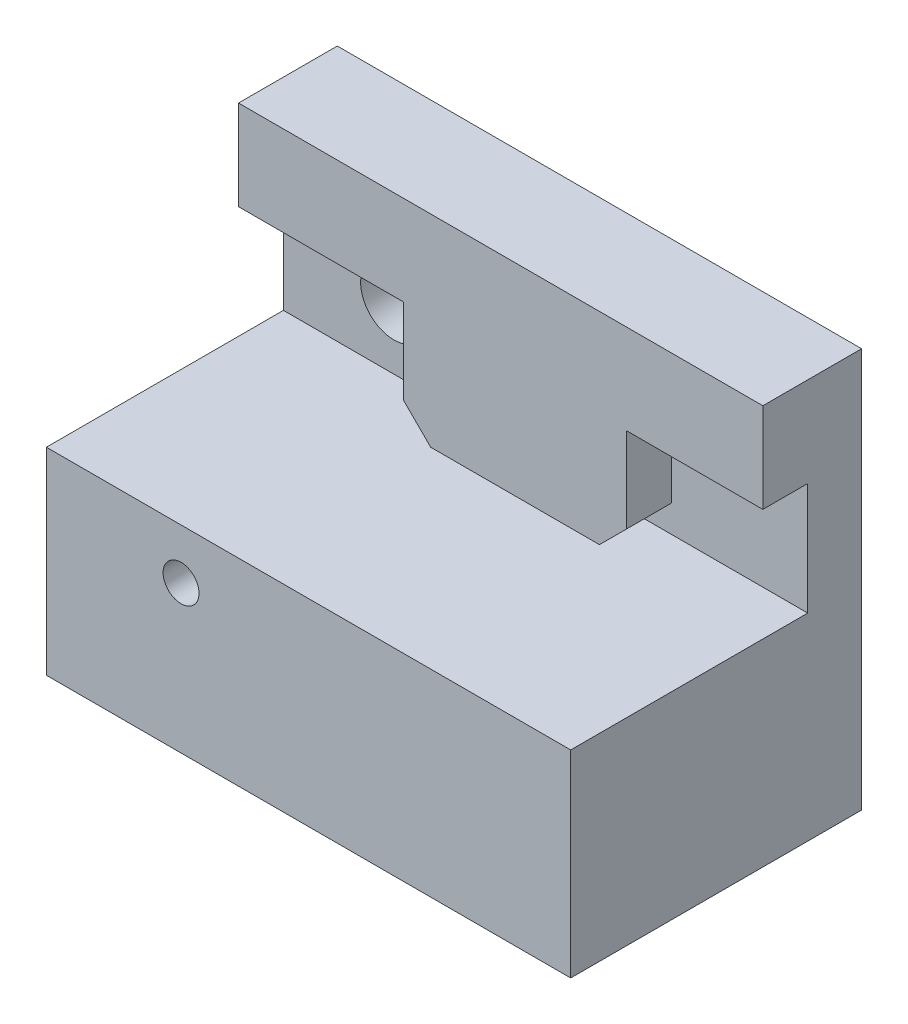
from build123d import *

# Parameters (mm, degrees)
SKETCH1_W           = 29.2
SKETCH1_H           = 11
SKETCH1_R           = 1
BOSS_EXTRUDE1_DEPTH = 13.2
SKETCH6_R           = 1.85
CUT_EXTRUDE3_DEPTH  = 11.5
BOSS_EXTRUDE4_DEPTH = 2.5
SKETCH8_R           = 1.85
BOSS_EXTRUDE5_DEPTH = 3


with BuildPart() as part:
    # Sketch1 → Boss-Extrude1 (new body)
    with BuildSketch(Plane.XY):
        with Locations((14.6, 5.5)):
            Rectangle(SKETCH1_W, SKETCH1_H)
        with Locations((7.5, 8.2)):
            Circle(SKETCH1_R, mode=Mode.SUBTRACT)
    extrude(amount=BOSS_EXTRUDE1_DEPTH)

    # Sketch6 → Cut-Extrude3 (cut)
    with BuildSketch(Plane(origin=(0, 0, 0), x_dir=(-1, 0, 0), z_dir=(0, 0, -1))):
        with Locations((-7.5, 8.2)):
            Circle(SKETCH6_R)
    extrude(amount=-CUT_EXTRUDE3_DEPTH, mode=Mode.SUBTRACT)

    # Sketch7 → Boss-Extrude4 (add)
    with BuildSketch(Plane(origin=(0, 0, 0), x_dir=(-1, 0, 0), z_dir=(0, 0, -1))):
        Polygon((-20.1, 11), (-10.7, 11), (-9.2, 12.5), (-9.2, 17.25), (0, 17.25), (0, 22.25), (-29.2, 22.25), (-29.2, 17.25), (-21.6, 17.25), (-21.6, 12.5), align=None)
    extrude(amount=-BOSS_EXTRUDE4_DEPTH)

    # Sketch8 → Boss-Extrude5 (add)
    with BuildSketch(Plane(origin=(0, 0, 0), x_dir=(-1, 0, 0), z_dir=(0, 0, -1))):
        Polygon((-29.2, 22.25), (0, 22.25), (0, 16), (0, 10.75), (0, 0), (-29.2, 0), (-29.2, 10.75), (-29.2, 16), align=None)
        with Locations((-7.5, 8.2)):
            Circle(SKETCH8_R, mode=Mode.SUBTRACT)
        with Locations((-6.15, 14.5)):
            Circle(SKETCH8_R, mode=Mode.SUBTRACT)
    extrude(amount=BOSS_EXTRUDE5_DEPTH)


solid = part.part
